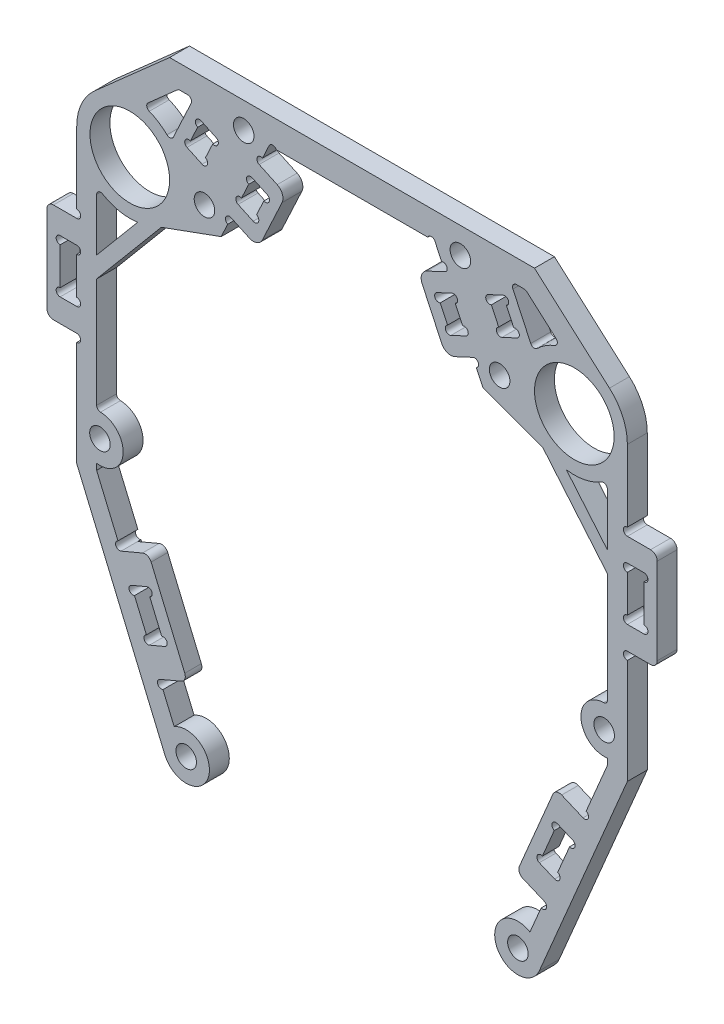
from build123d import *

# Parameters (mm, degrees)
SKETCH_1_R          = 6
EXTRUDE_1_DEPTH     = 1.5
EXTRUDE_2_DEPTH     = 3
SKETCH_6_R          = 0.6
CUT_EXTRUDE_2_DEPTH = 4
FILLET_1_R          = 1.5
SKETCH_7_R          = 1.55
CUT_EXTRUDE_3_DEPTH = 4
CUT_EXTRUDE_4_DEPTH = 4
FILLET_2_R          = 0.6
SKETCH_9_R          = 1.55
EXTRUDE_3_DEPTH     = 3
FILLET_3_R          = 0.6
EXTRUDE_4_DEPTH     = 3
SKETCH_11_R         = 0.6
CUT_EXTRUDE_5_DEPTH = 4
FILLET_4_R          = 1
EXTRUDE_5_DEPTH     = 3
SKETCH_13_R         = 1.55
EXTRUDE_6_DEPTH     = 3
EXTRUDE_9_DEPTH     = 2.5
FILLET_8_R          = 1
SKETCH_18_R         = 0.6
CUT_EXTRUDE_7_DEPTH = 4


with BuildPart() as part:
    # 草图1 → 凸台-拉伸1 (new body, symmetric)
    with BuildSketch(Plane.XY):
        with BuildLine():
            Line((-12.5, 12), (12.5, 12))
            Line((12.5, 12), (19.728184266, -3.500891181))
            Line((19.728184266, -3.500891181), (30.763838853, -7.517540966))
            ThreePointArc((30.763838853, -7.517540966), (40.374225454, -4.092068476), (38.803964436, 5.988986664))
            Line((38.803964436, 5.988986664), (27.5, 16))
            Line((27.5, 16), (-27.5, 16))
            Line((-27.5, 16), (-38.803964436, 5.988986664))
            ThreePointArc((-38.803964436, 5.988986664), (-40.374225454, -4.092068476), (-30.763838853, -7.517540966))
            Line((-30.763838853, -7.517540966), (-19.728184266, -3.500891181))
            Line((-19.728184266, -3.500891181), (-12.5, 12))
        make_face()
        with Locations((-33.5, 0)):
            Circle(SKETCH_1_R, mode=Mode.SUBTRACT)
        with Locations((33.5, 0)):
            Circle(SKETCH_1_R, mode=Mode.SUBTRACT)
    extrude(amount=EXTRUDE_1_DEPTH, both=True)

    # 草图5 → 凸台-拉伸2 (add)
    with BuildSketch(Plane.XY.offset(1.5)):
        Polygon((-14.001000824, 8.781093345), (-9.922615783, 6.879311167), (-14.1487984, -2.183766703), (-18.227183442, -0.281984526), (-17.170637787, 1.983784942), (-14.90486832, 0.927239288), (-12.791777011, 5.458778223), (-15.057546479, 6.515323877), align=None)
        Polygon((14.90486832, 0.927239288), (17.170637787, 1.983784942), (18.227183442, -0.281984526), (14.1487984, -2.183766703), (9.922615783, 6.879311167), (14.001000824, 8.781093345), (15.057546479, 6.515323877), (12.791777011, 5.458778223), align=None)
    extrude(amount=-EXTRUDE_2_DEPTH)

    # 草图6 → 切除-拉伸2 (cut, through all)
    with BuildSketch(Plane.XY.offset(1.5)):
        with Locations((-15.311117436, 5.971539205)):
            Circle(SKETCH_6_R)
        with Locations((-13.045347968, 4.914993551)):
            Circle(SKETCH_6_R)
        with Locations((-16.91706683, 2.527569614)):
            Circle(SKETCH_6_R)
        with Locations((-14.651297363, 1.47102396)):
            Circle(SKETCH_6_R)
        with Locations((-13.747429867, 9.324878017)):
            Circle(SKETCH_6_R)
        with Locations((-18.480754399, -0.825769198)):
            Circle(SKETCH_6_R)
        with Locations((18.480754399, -0.825769198)):
            Circle(SKETCH_6_R)
        with Locations((13.747429867, 9.324878017)):
            Circle(SKETCH_6_R)
        with Locations((14.651297363, 1.47102396)):
            Circle(SKETCH_6_R)
        with Locations((16.91706683, 2.527569614)):
            Circle(SKETCH_6_R)
        with Locations((13.045347968, 4.914993551)):
            Circle(SKETCH_6_R)
        with Locations((15.311117436, 5.971539205)):
            Circle(SKETCH_6_R)
        with Locations((-11.956215328, 11.746429043)):
            Circle(SKETCH_6_R)
        with Locations((11.956215328, 11.746429043)):
            Circle(SKETCH_6_R)
    extrude(amount=-CUT_EXTRUDE_2_DEPTH, mode=Mode.SUBTRACT)

    # 圆角1
    fillet_1_edges = [part.edges().sort_by_distance(p)[0] for p in [
        (-9.922615783, 6.879311167, 0),
        (-14.1487984, -2.183766703, 0),
        (14.1487984, -2.183766703, 0),
        (9.922615783, 6.879311167, 0),
    ]]
    fillet(fillet_1_edges, radius=FILLET_1_R)

    # 草图7 → 切除-拉伸3 (cut, through all)
    with BuildSketch(Plane.XY.offset(1.5)):
        with Locations((-22.24449722, -0.615436184)):
            Circle(SKETCH_7_R)
        with Locations((-16.327841555, 12.072872835)):
            Circle(SKETCH_7_R)
        with Locations((22.24449722, -0.615436184)):
            Circle(SKETCH_7_R)
        with Locations((16.327841555, 12.072872835)):
            Circle(SKETCH_7_R)
    extrude(amount=-CUT_EXTRUDE_3_DEPTH, mode=Mode.SUBTRACT)

    # 草图8 → 切除-拉伸4 (cut, through all)
    with BuildSketch(Plane.XY.offset(1.5)):
        with BuildLine():
            Line((-26.172964956, 12.5), (-31.531802084, 7.754108393))
            ThreePointArc((-31.531802084, 7.754108393), (-29.20884675, 6.751740797), (-27.315064556, 5.074108154))
            Line((-27.315064556, 5.074108154), (-23.85231432, 12.5))
            Line((-23.85231432, 12.5), (-26.172964956, 12.5))
        make_face()
        with BuildLine():
            Line((-22.101342595, 5.607063857), (-21.002535115, 7.963464103))
            ThreePointArc((-21.002535115, 7.963464103), (-20.205179486, 8.253677818), (-20.495393201, 9.051033448))
            Line((-20.495393201, 9.051033448), (-22.761162668, 10.107579102))
            ThreePointArc((-22.761162668, 10.107579102), (-23.558518298, 9.817365387), (-23.268304582, 9.020009758))
            Line((-23.268304582, 9.020009758), (-24.367112063, 6.663609511))
            ThreePointArc((-24.367112063, 6.663609511), (-25.164467692, 6.373395796), (-24.874253977, 5.576040167))
            Line((-24.874253977, 5.576040167), (-22.608484509, 4.519494512))
            ThreePointArc((-22.608484509, 4.519494512), (-21.81112888, 4.809708228), (-22.101342595, 5.607063857))
        make_face()
        with BuildLine():
            Line((24.874253977, 5.576040167), (22.608484509, 4.519494512))
            ThreePointArc((22.608484509, 4.519494512), (21.81112888, 4.809708228), (22.101342595, 5.607063857))
            Line((22.101342595, 5.607063857), (21.002535115, 7.963464103))
            ThreePointArc((21.002535115, 7.963464103), (20.205179486, 8.253677818), (20.495393201, 9.051033448))
            Line((20.495393201, 9.051033448), (22.761162668, 10.107579102))
            ThreePointArc((22.761162668, 10.107579102), (23.558518298, 9.817365387), (23.268304582, 9.020009758))
            Line((23.268304582, 9.020009758), (24.367112063, 6.663609511))
            ThreePointArc((24.367112063, 6.663609511), (25.164467692, 6.373395796), (24.874253977, 5.576040167))
        make_face()
        with BuildLine():
            Line((26.172964956, 12.5), (23.85231432, 12.5))
            Line((23.85231432, 12.5), (27.315064556, 5.074108154))
            ThreePointArc((27.315064556, 5.074108154), (29.20884675, 6.751740797), (31.531802084, 7.754108393))
            Line((31.531802084, 7.754108393), (26.172964956, 12.5))
        make_face()
    extrude(amount=-CUT_EXTRUDE_4_DEPTH, mode=Mode.SUBTRACT)

    # 圆角2
    fillet_2_edges = [part.edges().sort_by_distance(p)[0] for p in [
        (26.172964956, 12.5, 0),
        (31.531802084, 7.754108393, 0),
        (27.315064556, 5.074108154, 0),
        (23.85231432, 12.5, 0),
        (-26.172964956, 12.5, 0),
        (-23.85231432, 12.5, 0),
        (-27.315064556, 5.074108154, 0),
        (-31.531802084, 7.754108393, 0),
    ]]
    fillet(fillet_2_edges, radius=FILLET_2_R)

    # 草图9 → 凸台-拉伸3 (add)
    with BuildSketch(Plane.XY.offset(1.5)):
        with BuildLine():
            Line((-41.5, 0), (-41.5, -39))
            ThreePointArc((-41.5, -39), (-35.354248689, -41.291287847), (-38.5, -35.535898385))
            Line((-38.5, -35.535898385), (-38.5, -6.244997998))
            ThreePointArc((-38.5, -6.244997998), (-40.711102551, -3.464101615), (-41.5, 0))
        make_face()
        with Locations((-38, -39)):
            Circle(SKETCH_9_R, mode=Mode.SUBTRACT)
    extrude_3 = extrude(amount=-EXTRUDE_3_DEPTH)

    # 镜向1: 凸台-拉伸3 across plane
    add(extrude_3.mirror(Plane(origin=(0, 0, 0), x_dir=(0, 0, 1), z_dir=(1, 0, 0))))

    # 圆角3
    fillet_3_edges = [part.edges().sort_by_distance(p)[0] for p in [
        (-38.5, -6.244997998, 0),
        (-38.5, -35.535898385, 0),
        (38.5, -6.244997998, 0),
        (38.5, -35.535898385, 0),
    ]]
    fillet(fillet_3_edges, radius=FILLET_3_R)

    # 草图10 → 凸台-拉伸4 (add)
    with BuildSketch(Plane.XY.offset(1.5)):
        Polygon((-41.5, -12), (-46, -12), (-46, -27), (-41.5, -27), (-41.5, -23.5), (-44, -23.5), (-44, -15.5), (-41.5, -15.5), align=None)
        Polygon((44, -15.5), (41.5, -15.5), (41.5, -12), (46, -12), (46, -27), (41.5, -27), (41.5, -23.5), (44, -23.5), align=None)
    extrude(amount=-EXTRUDE_4_DEPTH)

    # 草图11 → 切除-拉伸5 (cut, through all)
    with BuildSketch(Plane.XY.offset(1.5)):
        with Locations((-41.5, -11.4)):
            Circle(SKETCH_11_R)
        with Locations((-41.5, -27.6)):
            Circle(SKETCH_11_R)
        with Locations((-41.5, -22.9)):
            Circle(SKETCH_11_R)
        with Locations((-41.5, -16.1)):
            Circle(SKETCH_11_R)
        with Locations((-44, -16.1)):
            Circle(SKETCH_11_R)
        with Locations((-44, -22.9)):
            Circle(SKETCH_11_R)
        with Locations((44, -22.9)):
            Circle(SKETCH_11_R)
        with Locations((44, -16.1)):
            Circle(SKETCH_11_R)
        with Locations((41.5, -16.1)):
            Circle(SKETCH_11_R)
        with Locations((41.5, -22.9)):
            Circle(SKETCH_11_R)
        with Locations((41.5, -27.6)):
            Circle(SKETCH_11_R)
        with Locations((41.5, -11.4)):
            Circle(SKETCH_11_R)
    extrude(amount=-CUT_EXTRUDE_5_DEPTH, mode=Mode.SUBTRACT)

    # 圆角4
    fillet_4_edges = [part.edges().sort_by_distance(p)[0] for p in [
        (-46, -27, 0),
        (-46, -12, 0),
        (46, -12, 0),
        (46, -27, 0),
    ]]
    fillet(fillet_4_edges, radius=FILLET_4_R)

    # 草图12 → 凸台-拉伸5 (add)
    with BuildSketch(Plane.XY.offset(1.5)):
        Polygon((-38.5, -18.404558578), (-27.371644455, -5.142300877), (-28.903733341, -3.856725658), (-38.5, -15.293110924), align=None)
        Polygon((38.5, -15.293110924), (28.903733341, -3.856725658), (27.371644455, -5.142300877), (38.5, -18.404558578), align=None)
    extrude(amount=-EXTRUDE_5_DEPTH)

    # 草图13 → 凸台-拉伸6 (add)
    with BuildSketch(Plane.XY.offset(1.5)):
        with BuildLine():
            Line((-41.5, -39), (-41.5, -44))
            Line((-41.5, -44), (-28.22311464, -75.364379719))
            ThreePointArc((-28.22311464, -75.364379719), (-21.670358156, -75.078649708), (-26.810830659, -71.004855208))
            Line((-26.810830659, -71.004855208), (-38.5, -43.39118409))
            Line((-38.5, -43.39118409), (-38.5, -42.464101615))
            ThreePointArc((-38.5, -42.464101615), (-40.645751311, -41.291287847), (-41.5, -39))
        make_face()
        with Locations((-25, -74)):
            Circle(SKETCH_13_R, mode=Mode.SUBTRACT)
        with BuildLine():
            Line((41.5, -44), (28.22311464, -75.364379719))
            ThreePointArc((28.22311464, -75.364379719), (21.670358156, -75.078649708), (26.810830659, -71.004855208))
            Line((26.810830659, -71.004855208), (38.5, -43.39118409))
            Line((38.5, -43.39118409), (38.5, -42.464101615))
            ThreePointArc((38.5, -42.464101615), (40.645751311, -41.291287847), (41.5, -39))
            Line((41.5, -39), (41.5, -44))
        make_face()
        with Locations((25, -74)):
            Circle(SKETCH_13_R, mode=Mode.SUBTRACT)
    extrude(amount=-EXTRUDE_6_DEPTH)

    # 草图17 → 凸台-拉伸9 (add)
    with BuildSketch(Plane.XY.offset(1.5)):
        Polygon((-34.816191591, -52.093553856), (-30.672187054, -50.339351361), (-24.824845402, -64.152699818), (-28.96884994, -65.906902314), (-30.528141047, -62.223342725), (-28.225916304, -61.248785783), (-30.954675741, -54.802556503), (-33.256900484, -55.777113445), align=None)
        Polygon((30.954675741, -54.802556503), (33.256900484, -55.777113445), (34.816191591, -52.093553856), (30.672187054, -50.339351361), (24.824845402, -64.152699818), (28.96884994, -65.906902314), (30.528141047, -62.223342725), (28.225916304, -61.248785783), align=None)
    extrude(amount=-EXTRUDE_9_DEPTH)

    # 圆角8
    fillet_8_edges = [part.edges().sort_by_distance(p)[0] for p in [
        (-30.672187054, -50.339351361, 0.25),
        (-24.824845402, -64.152699818, 0.25),
        (24.824845402, -64.152699818, 0.25),
        (30.672187054, -50.339351361, 0.25),
    ]]
    fillet(fillet_8_edges, radius=FILLET_8_R)

    # 草图18 → 切除-拉伸7 (cut, through all)
    with BuildSketch(Plane.XY.offset(1.5)):
        with Locations((-33.023006818, -56.329647383)):
            Circle(SKETCH_18_R)
        with Locations((-30.720782075, -55.355090441)):
            Circle(SKETCH_18_R)
        with Locations((-30.762034713, -61.670808787)):
            Circle(SKETCH_18_R)
        with Locations((-28.45980997, -60.696251845)):
            Circle(SKETCH_18_R)
        with Locations((-28.734956274, -66.459436252)):
            Circle(SKETCH_18_R)
        with Locations((-35.050085257, -51.541019918)):
            Circle(SKETCH_18_R)
        with Locations((35.050085257, -51.541019918)):
            Circle(SKETCH_18_R)
        with Locations((28.734956274, -66.459436252)):
            Circle(SKETCH_18_R)
        with Locations((28.45980997, -60.696251845)):
            Circle(SKETCH_18_R)
        with Locations((30.762034713, -61.670808787)):
            Circle(SKETCH_18_R)
        with Locations((30.720782075, -55.355090441)):
            Circle(SKETCH_18_R)
        with Locations((33.023006818, -56.329647383)):
            Circle(SKETCH_18_R)
    extrude(amount=-CUT_EXTRUDE_7_DEPTH, mode=Mode.SUBTRACT)


solid = part.part
